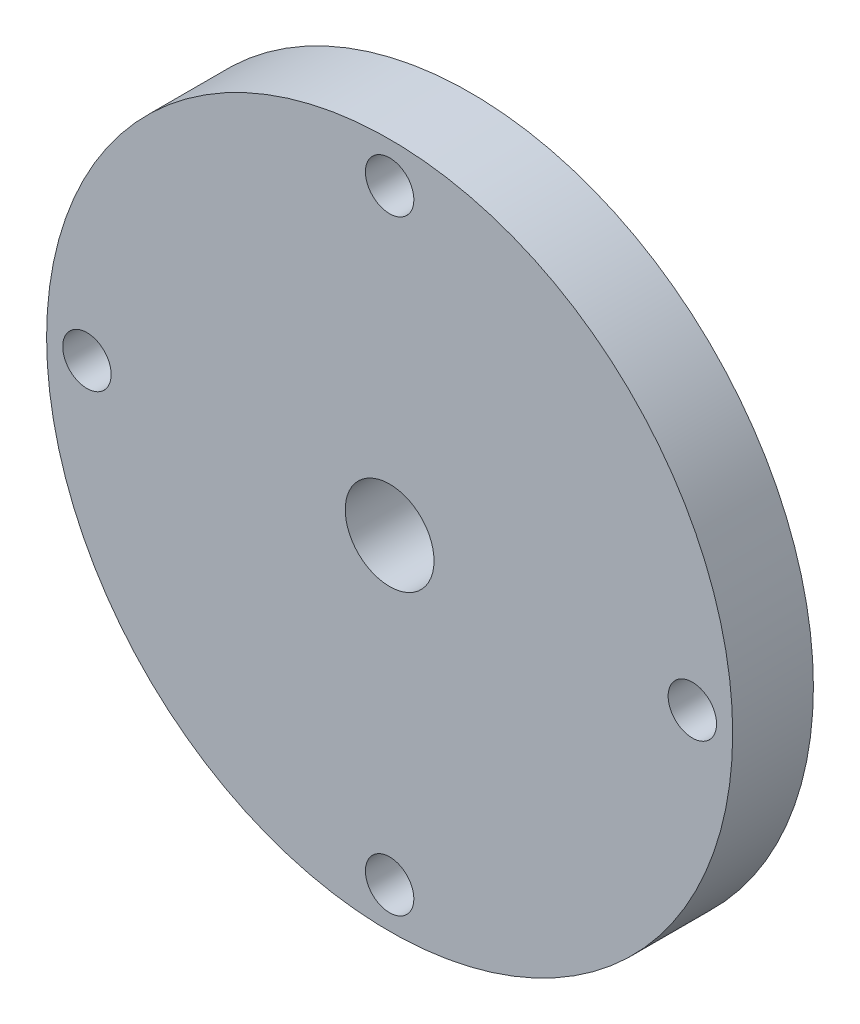
from build123d import *

# Parameters (mm, degrees)
ESQUISSE1_R        = 4.25
ESQUISSE1_R_2      = 0.3
ESQUISSE1_R_3      = 0.55
BOSS_EXTRU_1_DEPTH = 1


with BuildPart() as part:
    # Esquisse1 → Boss.-Extru.1 (new body)
    with BuildSketch(Plane.XY):
        Circle(ESQUISSE1_R)
        with Locations((0, 3.75)):
            Circle(ESQUISSE1_R_2, mode=Mode.SUBTRACT)
        Circle(ESQUISSE1_R_3, mode=Mode.SUBTRACT)
        with Locations((3.75, 0)):
            Circle(ESQUISSE1_R_2, mode=Mode.SUBTRACT)
        with Locations((0, -3.75)):
            Circle(ESQUISSE1_R_2, mode=Mode.SUBTRACT)
        with Locations((-3.75, 0)):
            Circle(ESQUISSE1_R_2, mode=Mode.SUBTRACT)
    extrude(amount=BOSS_EXTRU_1_DEPTH)


solid = part.part
